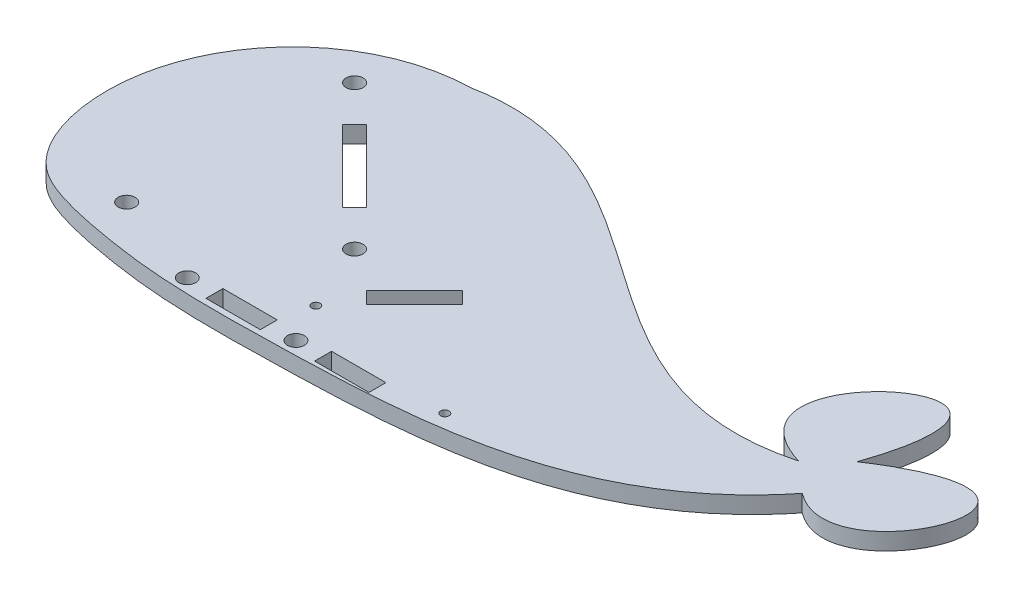
from build123d import *

# Parameters (mm, degrees)
SKETCH2_R           = 0.79375
SKETCH2_R_2         = 1.5875
BOSS_EXTRUDE1_DEPTH = 3.175
SKETCH6_R           = 1.5875
SKETCH6_W           = 10.16
SKETCH6_H           = 3.175
CUT_EXTRUDE7_DEPTH  = 3.175


with BuildPart() as part:
    # Sketch2 → Boss-Extrude1 (new body)
    with BuildSketch(Plane(origin=(0, 0, 0), x_dir=(1, 0, 0), z_dir=(0, 1, 0))):
        with BuildLine():
            add(Edge.make_bspline(
                [(33.497009682, 65.232830434), (13.835847475, 64.776830272), (-6.409764626, 41.73429338), (3.622545376, 12.806591648), (14.401932892, 8.751185323), (21.866269504, 7.208900872), (35.976831579, 4.999507913), (73.987200978, 5.536603608), (111.714388313, 7.447421867), (130.159055539, 30.527662162)],
                knots=[0, 0, 0, 0, 0.267337016, 0.357505563, 0.391567423, 0.432956685, 0.471433917, 0.602900813, 1, 1, 1, 1], degree=3))
            add(Edge.make_bspline(
                [(130.159055539, 30.527662162), (146.215631414, 18.430501295), (163.066903523, 62.486021671), (130.159055539, 40.776168229)],
                knots=[0, 0, 0, 0, 1, 1, 1, 1], degree=3))
            add(Edge.make_bspline(
                [(124.56896132, 35.418994603), (97.971761813, 43.753617373), (143.399689125, 78.887876507), (130.159055539, 40.776168229)],
                knots=[0, 0, 0, 0, 1, 1, 1, 1], degree=3))
            add(Edge.make_bspline(
                [(33.497009682, 65.232830434), (68.171069047, 72.094325348), (87.442597609, 25.509886786), (124.56896132, 35.418994603)],
                knots=[0, 0, 0, 0, 1, 1, 1, 1], degree=3))
        make_face()
        with Locations((54.270772962, 15.437527161)):
            Circle(SKETCH2_R, mode=Mode.SUBTRACT)
        with Locations((83.780763613, 10.057323349)):
            Circle(SKETCH2_R, mode=Mode.SUBTRACT)
        with Locations((21.794225131, 55.167022129)):
            Circle(SKETCH2_R_2, mode=Mode.SUBTRACT)
        with Locations((48.734993495, 28.226253766)):
            Circle(SKETCH2_R_2, mode=Mode.SUBTRACT)
        with Locations((19.8209749, 14.519501599)):
            Circle(SKETCH2_R_2, mode=Mode.SUBTRACT)
        Polygon((27.406885207, 47.309298023), (40.877269389, 33.838913841), (43.122333419, 36.083977871), (29.651949237, 49.554362053), align=None, mode=Mode.SUBTRACT)
        Polygon((58.837781631, 20.36852966), (67.818037752, 29.348785781), (65.572973722, 31.593849811), (56.5927176, 22.61359369), align=None, mode=Mode.SUBTRACT)
    extrude(amount=BOSS_EXTRUDE1_DEPTH)

    # Sketch6 → Cut-Extrude7 (cut)
    with BuildSketch(Plane(origin=(0, 3.175, 0), x_dir=(1, 0, 0), z_dir=(0, 1, 0))):
        with Locations((37.731588031, 7.940901599)):
            Circle(SKETCH6_R)
        with Locations((47.891588031, 7.940901599)):
            Rectangle(SKETCH6_W, SKETCH6_H)
        with Locations((58.051588031, 7.940901599)):
            Circle(SKETCH6_R)
        with Locations((68.211588031, 7.940901599)):
            Rectangle(SKETCH6_W, SKETCH6_H)
    extrude(amount=-CUT_EXTRUDE7_DEPTH, mode=Mode.SUBTRACT)


solid = part.part
